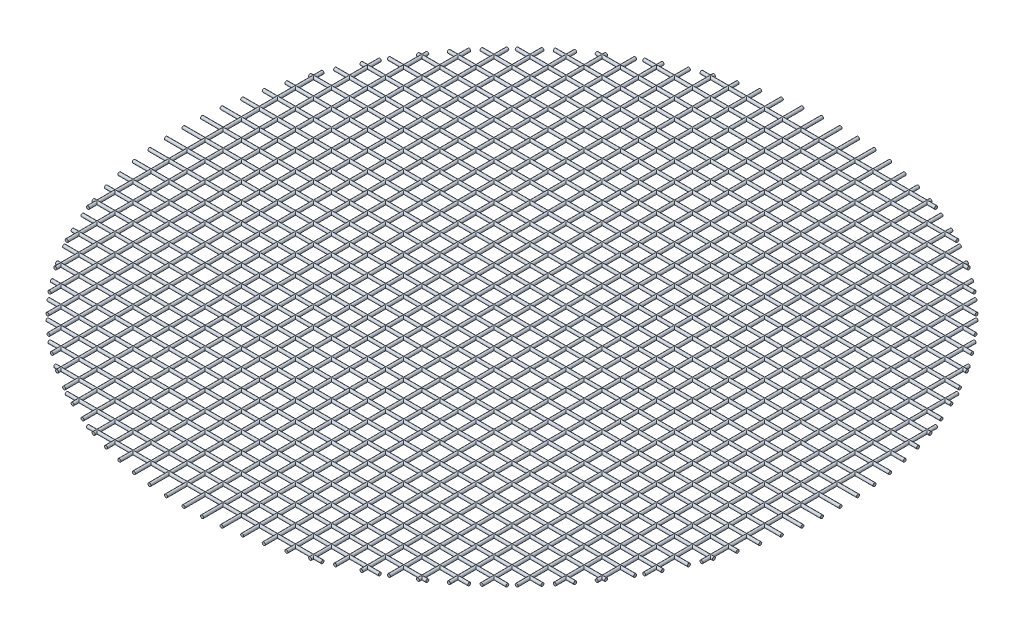
from build123d import *

# Parameters (mm, degrees)
SKETCH11_R                  = 10.668
PIPE_0_5_SCH_40_17_DEPTH    = 1650.804603822
SKETCH11_ON_SEGMENT_2_R     = 10.668
PIPE_0_5_SCH_40_17_2_DEPTH  = 2203.221241728
SKETCH11_ON_SEGMENT_3_R     = 10.668
PIPE_0_5_SCH_40_17_3_DEPTH  = 2618.048861271
SKETCH11_ON_SEGMENT_4_R     = 10.668
PIPE_0_5_SCH_40_17_4_DEPTH  = 2953.835445654
SKETCH11_ON_SEGMENT_5_R     = 10.668
PIPE_0_5_SCH_40_17_5_DEPTH  = 3235.286052268
SKETCH11_ON_SEGMENT_6_R     = 10.668
PIPE_0_5_SCH_40_17_6_DEPTH  = 3475.625963765
SKETCH11_ON_SEGMENT_7_R     = 10.668
PIPE_0_5_SCH_40_17_7_DEPTH  = 3682.912412752
SKETCH11_ON_SEGMENT_8_R     = 10.668
PIPE_0_5_SCH_40_17_8_DEPTH  = 3862.470691151
SKETCH11_ON_SEGMENT_9_R     = 10.668
PIPE_0_5_SCH_40_17_9_DEPTH  = 4018.019890444
SKETCH11_ON_SEGMENT_10_R    = 10.668
PIPE_0_5_SCH_40_17_10_DEPTH = 4152.259124862
SKETCH11_ON_SEGMENT_11_R    = 10.668
PIPE_0_5_SCH_40_17_11_DEPTH = 4267.2
SKETCH11_ON_SEGMENT_12_R    = 10.668
PIPE_0_5_SCH_40_17_12_DEPTH = 4364.367518897
SKETCH11_ON_SEGMENT_13_R    = 10.668
PIPE_0_5_SCH_40_17_13_DEPTH = 4444.927427979
SKETCH11_ON_SEGMENT_14_R    = 10.668
PIPE_0_5_SCH_40_17_14_DEPTH = 4509.769821177
SKETCH11_ON_SEGMENT_15_R    = 10.668
PIPE_0_5_SCH_40_17_15_DEPTH = 4559.565312615
SKETCH11_ON_SEGMENT_16_R    = 10.668
PIPE_0_5_SCH_40_17_16_DEPTH = 4594.803133976
SKETCH11_ON_SEGMENT_17_R    = 10.668
PIPE_0_5_SCH_40_17_17_DEPTH = 4615.816703466
SKETCH11_ON_SEGMENT_18_R    = 10.668
PIPE_0_5_SCH_40_17_18_DEPTH = 4622.8
SKETCH12_R                  = 10.668
PIPE_0_5_SCH_40_16_DEPTH    = 1650.804603822
SKETCH12_ON_SEGMENT_2_R     = 10.668
PIPE_0_5_SCH_40_16_2_DEPTH  = 2203.221241728
SKETCH12_ON_SEGMENT_3_R     = 10.668
PIPE_0_5_SCH_40_16_3_DEPTH  = 2618.048861271
SKETCH12_ON_SEGMENT_4_R     = 10.668
PIPE_0_5_SCH_40_16_4_DEPTH  = 2953.835445654
SKETCH12_ON_SEGMENT_5_R     = 10.668
PIPE_0_5_SCH_40_16_5_DEPTH  = 3235.286052268
SKETCH12_ON_SEGMENT_6_R     = 10.668
PIPE_0_5_SCH_40_16_6_DEPTH  = 3475.625963765
SKETCH12_ON_SEGMENT_7_R     = 10.668
PIPE_0_5_SCH_40_16_7_DEPTH  = 3682.912412752
SKETCH12_ON_SEGMENT_8_R     = 10.668
PIPE_0_5_SCH_40_16_8_DEPTH  = 3862.470691151
SKETCH12_ON_SEGMENT_9_R     = 10.668
PIPE_0_5_SCH_40_16_9_DEPTH  = 4018.019890444
SKETCH12_ON_SEGMENT_10_R    = 10.668
PIPE_0_5_SCH_40_16_10_DEPTH = 4152.259124862
SKETCH12_ON_SEGMENT_11_R    = 10.668
PIPE_0_5_SCH_40_16_11_DEPTH = 4267.2
SKETCH12_ON_SEGMENT_12_R    = 10.668
PIPE_0_5_SCH_40_16_12_DEPTH = 4364.367518897
SKETCH12_ON_SEGMENT_13_R    = 10.668
PIPE_0_5_SCH_40_16_13_DEPTH = 4444.927427979
SKETCH12_ON_SEGMENT_14_R    = 10.668
PIPE_0_5_SCH_40_16_14_DEPTH = 4509.769821177
SKETCH12_ON_SEGMENT_15_R    = 10.668
PIPE_0_5_SCH_40_16_15_DEPTH = 4559.565312615
SKETCH12_ON_SEGMENT_16_R    = 10.668
PIPE_0_5_SCH_40_16_16_DEPTH = 4594.803133976
SKETCH12_ON_SEGMENT_17_R    = 10.668
PIPE_0_5_SCH_40_16_17_DEPTH = 4615.816703466
SKETCH12_ON_SEGMENT_18_R    = 10.668
PIPE_0_5_SCH_40_16_18_DEPTH = 4622.8


with BuildPart() as part:
    # Sketch11 → Pipe 0.5 SCH 40(17) (new body)
    with BuildSketch(Plane(origin=(-825.402301911, 0, -2159), x_dir=(0, 0, -1), z_dir=(1, 0, 0))):
        Circle(SKETCH11_R)
    extrude(amount=PIPE_0_5_SCH_40_17_DEPTH)


with BuildPart() as body_2:
    # Sketch11 on segment 2 (carried to segment 2) → Pipe 0.5 SCH 40_17 2 (new body)
    with BuildSketch(Plane(origin=(-1101.610620864, 0, -2032), x_dir=(0, 0, -1), z_dir=(1, 0, 0))):
        Circle(SKETCH11_ON_SEGMENT_2_R)
    extrude(amount=PIPE_0_5_SCH_40_17_2_DEPTH)


with BuildPart() as body_3:
    # Sketch11 on segment 3 (carried to segment 3) → Pipe 0.5 SCH 40_17 3 (new body)
    with BuildSketch(Plane(origin=(-1309.024430635, 0, -1905), x_dir=(0, 0, -1), z_dir=(1, 0, 0))):
        Circle(SKETCH11_ON_SEGMENT_3_R)
    extrude(amount=PIPE_0_5_SCH_40_17_3_DEPTH)


with BuildPart() as body_4:
    # Sketch11 on segment 4 (carried to segment 4) → Pipe 0.5 SCH 40_17 4 (new body)
    with BuildSketch(Plane(origin=(-1476.917722827, 0, -1778), x_dir=(0, 0, -1), z_dir=(1, 0, 0))):
        Circle(SKETCH11_ON_SEGMENT_4_R)
    extrude(amount=PIPE_0_5_SCH_40_17_4_DEPTH)


with BuildPart() as body_5:
    # Sketch11 on segment 5 (carried to segment 5) → Pipe 0.5 SCH 40_17 5 (new body)
    with BuildSketch(Plane(origin=(-1617.643026134, 0, -1651), x_dir=(0, 0, -1), z_dir=(1, 0, 0))):
        Circle(SKETCH11_ON_SEGMENT_5_R)
    extrude(amount=PIPE_0_5_SCH_40_17_5_DEPTH)


with BuildPart() as body_6:
    # Sketch11 on segment 6 (carried to segment 6) → Pipe 0.5 SCH 40_17 6 (new body)
    with BuildSketch(Plane(origin=(-1737.812981883, 0, -1524), x_dir=(0, 0, -1), z_dir=(1, 0, 0))):
        Circle(SKETCH11_ON_SEGMENT_6_R)
    extrude(amount=PIPE_0_5_SCH_40_17_6_DEPTH)


with BuildPart() as body_7:
    # Sketch11 on segment 7 (carried to segment 7) → Pipe 0.5 SCH 40_17 7 (new body)
    with BuildSketch(Plane(origin=(-1841.456206376, 0, -1397), x_dir=(0, 0, -1), z_dir=(1, 0, 0))):
        Circle(SKETCH11_ON_SEGMENT_7_R)
    extrude(amount=PIPE_0_5_SCH_40_17_7_DEPTH)


with BuildPart() as body_8:
    # Sketch11 on segment 8 (carried to segment 8) → Pipe 0.5 SCH 40_17 8 (new body)
    with BuildSketch(Plane(origin=(-1931.235345575, 0, -1270), x_dir=(0, 0, -1), z_dir=(1, 0, 0))):
        Circle(SKETCH11_ON_SEGMENT_8_R)
    extrude(amount=PIPE_0_5_SCH_40_17_8_DEPTH)


with BuildPart() as body_9:
    # Sketch11 on segment 9 (carried to segment 9) → Pipe 0.5 SCH 40_17 9 (new body)
    with BuildSketch(Plane(origin=(-2009.009945222, 0, -1143), x_dir=(0, 0, -1), z_dir=(1, 0, 0))):
        Circle(SKETCH11_ON_SEGMENT_9_R)
    extrude(amount=PIPE_0_5_SCH_40_17_9_DEPTH)


with BuildPart() as body_10:
    # Sketch11 on segment 10 (carried to segment 10) → Pipe 0.5 SCH 40_17 10 (new body)
    with BuildSketch(Plane(origin=(-2076.129562431, 0, -1016), x_dir=(0, 0, -1), z_dir=(1, 0, 0))):
        Circle(SKETCH11_ON_SEGMENT_10_R)
    extrude(amount=PIPE_0_5_SCH_40_17_10_DEPTH)


with BuildPart() as body_11:
    # Sketch11 on segment 11 (carried to segment 11) → Pipe 0.5 SCH 40_17 11 (new body)
    with BuildSketch(Plane(origin=(-2133.6, 0, -889), x_dir=(0, 0, -1), z_dir=(1, 0, 0))):
        Circle(SKETCH11_ON_SEGMENT_11_R)
    extrude(amount=PIPE_0_5_SCH_40_17_11_DEPTH)


with BuildPart() as body_12:
    # Sketch11 on segment 12 (carried to segment 12) → Pipe 0.5 SCH 40_17 12 (new body)
    with BuildSketch(Plane(origin=(-2182.183759448, 0, -762), x_dir=(0, 0, -1), z_dir=(1, 0, 0))):
        Circle(SKETCH11_ON_SEGMENT_12_R)
    extrude(amount=PIPE_0_5_SCH_40_17_12_DEPTH)


with BuildPart() as body_13:
    # Sketch11 on segment 13 (carried to segment 13) → Pipe 0.5 SCH 40_17 13 (new body)
    with BuildSketch(Plane(origin=(-2222.463713989, 0, -635), x_dir=(0, 0, -1), z_dir=(1, 0, 0))):
        Circle(SKETCH11_ON_SEGMENT_13_R)
    extrude(amount=PIPE_0_5_SCH_40_17_13_DEPTH)


with BuildPart() as body_14:
    # Sketch11 on segment 14 (carried to segment 14) → Pipe 0.5 SCH 40_17 14 (new body)
    with BuildSketch(Plane(origin=(-2254.884910589, 0, -508), x_dir=(0, 0, -1), z_dir=(1, 0, 0))):
        Circle(SKETCH11_ON_SEGMENT_14_R)
    extrude(amount=PIPE_0_5_SCH_40_17_14_DEPTH)


with BuildPart() as body_15:
    # Sketch11 on segment 15 (carried to segment 15) → Pipe 0.5 SCH 40_17 15 (new body)
    with BuildSketch(Plane(origin=(-2279.782656307, 0, -381), x_dir=(0, 0, -1), z_dir=(1, 0, 0))):
        Circle(SKETCH11_ON_SEGMENT_15_R)
    extrude(amount=PIPE_0_5_SCH_40_17_15_DEPTH)


with BuildPart() as body_16:
    # Sketch11 on segment 16 (carried to segment 16) → Pipe 0.5 SCH 40_17 16 (new body)
    with BuildSketch(Plane(origin=(-2297.401566988, 0, -254), x_dir=(0, 0, -1), z_dir=(1, 0, 0))):
        Circle(SKETCH11_ON_SEGMENT_16_R)
    extrude(amount=PIPE_0_5_SCH_40_17_16_DEPTH)


with BuildPart() as body_17:
    # Sketch11 on segment 17 (carried to segment 17) → Pipe 0.5 SCH 40_17 17 (new body)
    with BuildSketch(Plane(origin=(-2307.908351733, 0, -127), x_dir=(0, 0, -1), z_dir=(1, 0, 0))):
        Circle(SKETCH11_ON_SEGMENT_17_R)
    extrude(amount=PIPE_0_5_SCH_40_17_17_DEPTH)


with BuildPart() as body_18:
    # Sketch11 on segment 18 (carried to segment 18) → Pipe 0.5 SCH 40_17 18 (new body)
    with BuildSketch(Plane(origin=(-2311.4, 0, 0), x_dir=(0, 0, -1), z_dir=(1, 0, 0))):
        Circle(SKETCH11_ON_SEGMENT_18_R)
    extrude(amount=PIPE_0_5_SCH_40_17_18_DEPTH)


with BuildPart() as body_19:
    # Sketch12 → Pipe 0.5 SCH 40(16) (new body)
    with BuildSketch(Plane(origin=(2159, 0, -825.402301911), x_dir=(1, 0, 0), z_dir=(0, 0, 1))):
        Circle(SKETCH12_R)
    extrude(amount=PIPE_0_5_SCH_40_16_DEPTH)


with BuildPart() as body_20:
    # Sketch12 on segment 2 (carried to segment 2) → Pipe 0.5 SCH 40_16 2 (new body)
    with BuildSketch(Plane(origin=(2032, 0, -1101.610620864), x_dir=(1, 0, 0), z_dir=(0, 0, 1))):
        Circle(SKETCH12_ON_SEGMENT_2_R)
    extrude(amount=PIPE_0_5_SCH_40_16_2_DEPTH)


with BuildPart() as body_21:
    # Sketch12 on segment 3 (carried to segment 3) → Pipe 0.5 SCH 40_16 3 (new body)
    with BuildSketch(Plane(origin=(1905, 0, -1309.024430635), x_dir=(1, 0, 0), z_dir=(0, 0, 1))):
        Circle(SKETCH12_ON_SEGMENT_3_R)
    extrude(amount=PIPE_0_5_SCH_40_16_3_DEPTH)


with BuildPart() as body_22:
    # Sketch12 on segment 4 (carried to segment 4) → Pipe 0.5 SCH 40_16 4 (new body)
    with BuildSketch(Plane(origin=(1778, 0, -1476.917722827), x_dir=(1, 0, 0), z_dir=(0, 0, 1))):
        Circle(SKETCH12_ON_SEGMENT_4_R)
    extrude(amount=PIPE_0_5_SCH_40_16_4_DEPTH)


with BuildPart() as body_23:
    # Sketch12 on segment 5 (carried to segment 5) → Pipe 0.5 SCH 40_16 5 (new body)
    with BuildSketch(Plane(origin=(1651, 0, -1617.643026134), x_dir=(1, 0, 0), z_dir=(0, 0, 1))):
        Circle(SKETCH12_ON_SEGMENT_5_R)
    extrude(amount=PIPE_0_5_SCH_40_16_5_DEPTH)


with BuildPart() as body_24:
    # Sketch12 on segment 6 (carried to segment 6) → Pipe 0.5 SCH 40_16 6 (new body)
    with BuildSketch(Plane(origin=(1524, 0, -1737.812981883), x_dir=(1, 0, 0), z_dir=(0, 0, 1))):
        Circle(SKETCH12_ON_SEGMENT_6_R)
    extrude(amount=PIPE_0_5_SCH_40_16_6_DEPTH)


with BuildPart() as body_25:
    # Sketch12 on segment 7 (carried to segment 7) → Pipe 0.5 SCH 40_16 7 (new body)
    with BuildSketch(Plane(origin=(1397, 0, -1841.456206376), x_dir=(1, 0, 0), z_dir=(0, 0, 1))):
        Circle(SKETCH12_ON_SEGMENT_7_R)
    extrude(amount=PIPE_0_5_SCH_40_16_7_DEPTH)


with BuildPart() as body_26:
    # Sketch12 on segment 8 (carried to segment 8) → Pipe 0.5 SCH 40_16 8 (new body)
    with BuildSketch(Plane(origin=(1270, 0, -1931.235345575), x_dir=(1, 0, 0), z_dir=(0, 0, 1))):
        Circle(SKETCH12_ON_SEGMENT_8_R)
    extrude(amount=PIPE_0_5_SCH_40_16_8_DEPTH)


with BuildPart() as body_27:
    # Sketch12 on segment 9 (carried to segment 9) → Pipe 0.5 SCH 40_16 9 (new body)
    with BuildSketch(Plane(origin=(1143, 0, -2009.009945222), x_dir=(1, 0, 0), z_dir=(0, 0, 1))):
        Circle(SKETCH12_ON_SEGMENT_9_R)
    extrude(amount=PIPE_0_5_SCH_40_16_9_DEPTH)


with BuildPart() as body_28:
    # Sketch12 on segment 10 (carried to segment 10) → Pipe 0.5 SCH 40_16 10 (new body)
    with BuildSketch(Plane(origin=(1016, 0, -2076.129562431), x_dir=(1, 0, 0), z_dir=(0, 0, 1))):
        Circle(SKETCH12_ON_SEGMENT_10_R)
    extrude(amount=PIPE_0_5_SCH_40_16_10_DEPTH)


with BuildPart() as body_29:
    # Sketch12 on segment 11 (carried to segment 11) → Pipe 0.5 SCH 40_16 11 (new body)
    with BuildSketch(Plane(origin=(889, 0, -2133.6), x_dir=(1, 0, 0), z_dir=(0, 0, 1))):
        Circle(SKETCH12_ON_SEGMENT_11_R)
    extrude(amount=PIPE_0_5_SCH_40_16_11_DEPTH)


with BuildPart() as body_30:
    # Sketch12 on segment 12 (carried to segment 12) → Pipe 0.5 SCH 40_16 12 (new body)
    with BuildSketch(Plane(origin=(762, 0, -2182.183759448), x_dir=(1, 0, 0), z_dir=(0, 0, 1))):
        Circle(SKETCH12_ON_SEGMENT_12_R)
    extrude(amount=PIPE_0_5_SCH_40_16_12_DEPTH)


with BuildPart() as body_31:
    # Sketch12 on segment 13 (carried to segment 13) → Pipe 0.5 SCH 40_16 13 (new body)
    with BuildSketch(Plane(origin=(635, 0, -2222.463713989), x_dir=(1, 0, 0), z_dir=(0, 0, 1))):
        Circle(SKETCH12_ON_SEGMENT_13_R)
    extrude(amount=PIPE_0_5_SCH_40_16_13_DEPTH)


with BuildPart() as body_32:
    # Sketch12 on segment 14 (carried to segment 14) → Pipe 0.5 SCH 40_16 14 (new body)
    with BuildSketch(Plane(origin=(508, 0, -2254.884910589), x_dir=(1, 0, 0), z_dir=(0, 0, 1))):
        Circle(SKETCH12_ON_SEGMENT_14_R)
    extrude(amount=PIPE_0_5_SCH_40_16_14_DEPTH)


with BuildPart() as body_33:
    # Sketch12 on segment 15 (carried to segment 15) → Pipe 0.5 SCH 40_16 15 (new body)
    with BuildSketch(Plane(origin=(381, 0, -2279.782656307), x_dir=(1, 0, 0), z_dir=(0, 0, 1))):
        Circle(SKETCH12_ON_SEGMENT_15_R)
    extrude(amount=PIPE_0_5_SCH_40_16_15_DEPTH)


with BuildPart() as body_34:
    # Sketch12 on segment 16 (carried to segment 16) → Pipe 0.5 SCH 40_16 16 (new body)
    with BuildSketch(Plane(origin=(254, 0, -2297.401566988), x_dir=(1, 0, 0), z_dir=(0, 0, 1))):
        Circle(SKETCH12_ON_SEGMENT_16_R)
    extrude(amount=PIPE_0_5_SCH_40_16_16_DEPTH)


with BuildPart() as body_35:
    # Sketch12 on segment 17 (carried to segment 17) → Pipe 0.5 SCH 40_16 17 (new body)
    with BuildSketch(Plane(origin=(127, 0, -2307.908351733), x_dir=(1, 0, 0), z_dir=(0, 0, 1))):
        Circle(SKETCH12_ON_SEGMENT_17_R)
    extrude(amount=PIPE_0_5_SCH_40_16_17_DEPTH)


with BuildPart() as body_36:
    # Sketch12 on segment 18 (carried to segment 18) → Pipe 0.5 SCH 40_16 18 (new body)
    with BuildSketch(Plane.XY.offset(-2311.4)):
        Circle(SKETCH12_ON_SEGMENT_18_R)
    extrude(amount=PIPE_0_5_SCH_40_16_18_DEPTH)


with BuildPart() as body_37:
    # Mirror1: mirrored copy
    add(body_9.part.mirror(Plane.XY))


with BuildPart() as body_38:
    # Mirror1 2: mirrored copy
    add(body_8.part.mirror(Plane.XY))


with BuildPart() as body_39:
    # Mirror1 3: mirrored copy
    add(body_7.part.mirror(Plane.XY))


with BuildPart() as body_40:
    # Mirror1 4: mirrored copy
    add(body_6.part.mirror(Plane.XY))


with BuildPart() as body_41:
    # Mirror1 5: mirrored copy
    add(body_5.part.mirror(Plane.XY))


with BuildPart() as body_42:
    # Mirror1 6: mirrored copy
    add(body_17.part.mirror(Plane.XY))


with BuildPart() as body_43:
    # Mirror1 7: mirrored copy
    add(body_4.part.mirror(Plane.XY))


with BuildPart() as body_44:
    # Mirror1 8: mirrored copy
    add(body_16.part.mirror(Plane.XY))


with BuildPart() as body_45:
    # Mirror1 9: mirrored copy
    add(body_3.part.mirror(Plane.XY))


with BuildPart() as body_46:
    # Mirror1 10: mirrored copy
    add(body_15.part.mirror(Plane.XY))


with BuildPart() as body_47:
    # Mirror1 11: mirrored copy
    add(body_2.part.mirror(Plane.XY))


with BuildPart() as body_48:
    # Mirror1 12: mirrored copy
    add(body_14.part.mirror(Plane.XY))


with BuildPart() as body_49:
    # Mirror1 13: mirrored copy
    add(part.part.mirror(Plane.XY))


with BuildPart() as body_50:
    # Mirror1 14: mirrored copy
    add(body_13.part.mirror(Plane.XY))


with BuildPart() as body_51:
    # Mirror1 15: mirrored copy
    add(body_12.part.mirror(Plane.XY))


with BuildPart() as body_52:
    # Mirror1 16: mirrored copy
    add(body_11.part.mirror(Plane.XY))


with BuildPart() as body_53:
    # Mirror1 17: mirrored copy
    add(body_10.part.mirror(Plane.XY))


with BuildPart() as body_54:
    # Mirror2: mirrored copy
    add(body_30.part.mirror(Plane(origin=(0, 0, 0), x_dir=(0, 0, 1), z_dir=(1, 0, 0))))


with BuildPart() as body_55:
    # Mirror2 2: mirrored copy
    add(body_29.part.mirror(Plane(origin=(0, 0, 0), x_dir=(0, 0, 1), z_dir=(1, 0, 0))))


with BuildPart() as body_56:
    # Mirror2 3: mirrored copy
    add(body_28.part.mirror(Plane(origin=(0, 0, 0), x_dir=(0, 0, 1), z_dir=(1, 0, 0))))


with BuildPart() as body_57:
    # Mirror2 4: mirrored copy
    add(body_27.part.mirror(Plane(origin=(0, 0, 0), x_dir=(0, 0, 1), z_dir=(1, 0, 0))))


with BuildPart() as body_58:
    # Mirror2 5: mirrored copy
    add(body_26.part.mirror(Plane(origin=(0, 0, 0), x_dir=(0, 0, 1), z_dir=(1, 0, 0))))


with BuildPart() as body_59:
    # Mirror2 6: mirrored copy
    add(body_25.part.mirror(Plane(origin=(0, 0, 0), x_dir=(0, 0, 1), z_dir=(1, 0, 0))))


with BuildPart() as body_60:
    # Mirror2 7: mirrored copy
    add(body_24.part.mirror(Plane(origin=(0, 0, 0), x_dir=(0, 0, 1), z_dir=(1, 0, 0))))


with BuildPart() as body_61:
    # Mirror2 8: mirrored copy
    add(body_23.part.mirror(Plane(origin=(0, 0, 0), x_dir=(0, 0, 1), z_dir=(1, 0, 0))))


with BuildPart() as body_62:
    # Mirror2 9: mirrored copy
    add(body_35.part.mirror(Plane(origin=(0, 0, 0), x_dir=(0, 0, 1), z_dir=(1, 0, 0))))


with BuildPart() as body_63:
    # Mirror2 10: mirrored copy
    add(body_22.part.mirror(Plane(origin=(0, 0, 0), x_dir=(0, 0, 1), z_dir=(1, 0, 0))))


with BuildPart() as body_64:
    # Mirror2 11: mirrored copy
    add(body_34.part.mirror(Plane(origin=(0, 0, 0), x_dir=(0, 0, 1), z_dir=(1, 0, 0))))


with BuildPart() as body_65:
    # Mirror2 12: mirrored copy
    add(body_21.part.mirror(Plane(origin=(0, 0, 0), x_dir=(0, 0, 1), z_dir=(1, 0, 0))))


with BuildPart() as body_66:
    # Mirror2 13: mirrored copy
    add(body_33.part.mirror(Plane(origin=(0, 0, 0), x_dir=(0, 0, 1), z_dir=(1, 0, 0))))


with BuildPart() as body_67:
    # Mirror2 14: mirrored copy
    add(body_20.part.mirror(Plane(origin=(0, 0, 0), x_dir=(0, 0, 1), z_dir=(1, 0, 0))))


with BuildPart() as body_68:
    # Mirror2 15: mirrored copy
    add(body_32.part.mirror(Plane(origin=(0, 0, 0), x_dir=(0, 0, 1), z_dir=(1, 0, 0))))


with BuildPart() as body_69:
    # Mirror2 16: mirrored copy
    add(body_19.part.mirror(Plane(origin=(0, 0, 0), x_dir=(0, 0, 1), z_dir=(1, 0, 0))))


with BuildPart() as body_70:
    # Mirror2 17: mirrored copy
    add(body_31.part.mirror(Plane(origin=(0, 0, 0), x_dir=(0, 0, 1), z_dir=(1, 0, 0))))


solid = Compound([part.part, body_2.part, body_3.part, body_4.part, body_5.part, body_6.part, body_7.part, body_8.part, body_9.part, body_10.part, body_11.part, body_12.part, body_13.part, body_14.part, body_15.part, body_16.part, body_17.part, body_18.part, body_19.part, body_20.part, body_21.part, body_22.part, body_23.part, body_24.part, body_25.part, body_26.part, body_27.part, body_28.part, body_29.part, body_30.part, body_31.part, body_32.part, body_33.part, body_34.part, body_35.part, body_36.part, body_37.part, body_38.part, body_39.part, body_40.part, body_41.part, body_42.part, body_43.part, body_44.part, body_45.part, body_46.part, body_47.part, body_48.part, body_49.part, body_50.part, body_51.part, body_52.part, body_53.part, body_54.part, body_55.part, body_56.part, body_57.part, body_58.part, body_59.part, body_60.part, body_61.part, body_62.part, body_63.part, body_64.part, body_65.part, body_66.part, body_67.part, body_68.part, body_69.part, body_70.part])
